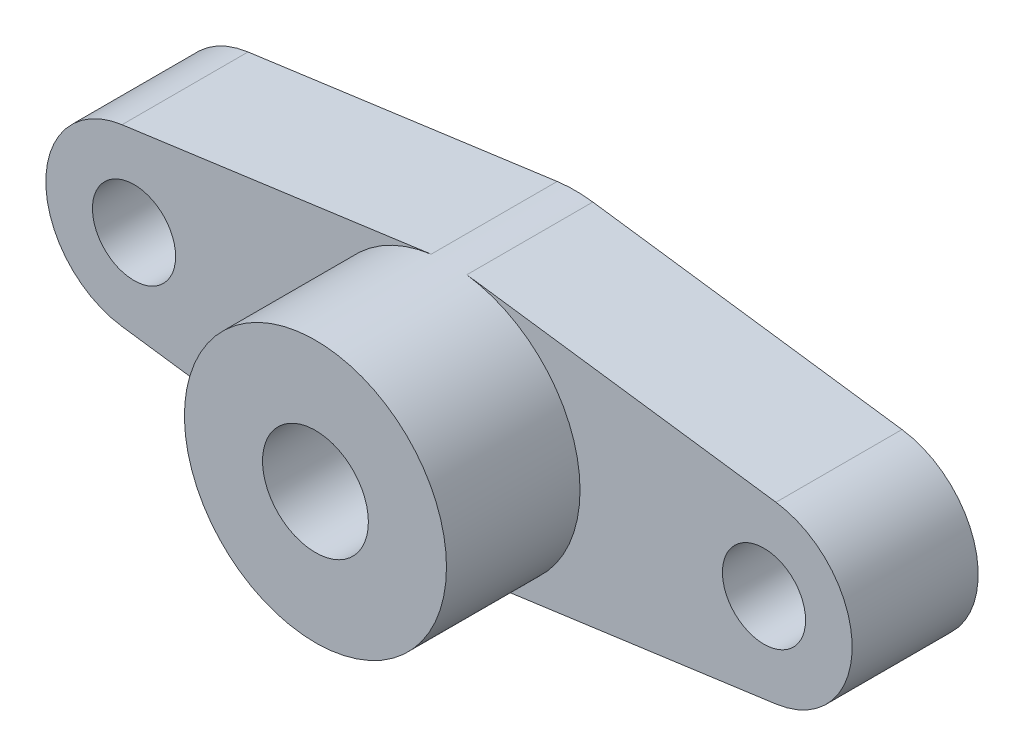
from build123d import *

# Parameters (mm, degrees)
SKETCH_1_W             = 32
SKETCH_1_H             = 10.4
SKETCH_1_R             = 0.5
EXTRUDE_1_DEPTH        = 5
SKETCH_2_R             = 5.2
SKETCH_2_R_2           = 0.5
EXTRUDE_2_DEPTH        = 5.3
CUT_EXTRUDE_1_DEPTH    = 5.3
HOLE_WIZARD_M4_1_D     = 3.3
HOLE_WIZARD_M4_1_DEPTH = 10.1
HOLE_WIZARD_M4_1_TIP   = 0.991420021
HOLE_WIZARD_M5_1_D     = 4.2
HOLE_WIZARD_M5_1_DEPTH = 22.4
HOLE_WIZARD_M5_1_TIP   = 1.2618073


with BuildPart() as part:
    # 草图1 → 凸台-拉伸1 (new body)
    with BuildSketch(Plane.XY):
        Rectangle(SKETCH_1_W, SKETCH_1_H)
        with Locations((-12.5, 0)):
            Circle(SKETCH_1_R, mode=Mode.SUBTRACT)
        with Locations((12.5, 0)):
            Circle(SKETCH_1_R, mode=Mode.SUBTRACT)
        Circle(SKETCH_1_R, mode=Mode.SUBTRACT)
    extrude(amount=EXTRUDE_1_DEPTH)

    # 草图2 → 凸台-拉伸2 (add)
    with BuildSketch(Plane.XY.offset(5)):
        Circle(SKETCH_2_R)
        Circle(SKETCH_2_R_2, mode=Mode.SUBTRACT)
    extrude(amount=EXTRUDE_2_DEPTH)

    # 草图3 → 切除-拉伸1 (cut)
    with BuildSketch(Plane.XY.offset(5)):
        with BuildLine():
            Line((-12.976, 3.46748093), (-0.7072, 5.151685953))
            ThreePointArc((-0.7072, 5.151685953), (-0.354424212, 5.187907428), (0, 5.2))
            Line((0, 5.2), (-16, 5.2))
            Line((-16, 5.2), (-16, 0))
            ThreePointArc((-16, 0), (-15.137802115, 2.300434742), (-12.976, 3.46748093))
        make_face()
        with BuildLine():
            ThreePointArc((0, -5.2), (-0.354424212, -5.187907428), (-0.7072, -5.151685953))
            Line((-0.7072, -5.151685953), (-12.976, -3.46748093))
            ThreePointArc((-12.976, -3.46748093), (-15.137802115, -2.300434742), (-16, 0))
            Line((-16, 0), (-16, -5.2))
            Line((-16, -5.2), (0, -5.2))
        make_face()
        with BuildLine():
            ThreePointArc((0.7072, -5.151685953), (0.354424212, -5.187907428), (0, -5.2))
            Line((0, -5.2), (16, -5.2))
            Line((16, -5.2), (16, 0))
            ThreePointArc((16, 0), (15.137802115, -2.300434742), (12.976, -3.46748093))
            Line((12.976, -3.46748093), (0.7072, -5.151685953))
        make_face()
        with BuildLine():
            Line((16, 5.2), (0, 5.2))
            ThreePointArc((0, 5.2), (0.354424212, 5.187907428), (0.7072, 5.151685953))
            Line((0.7072, 5.151685953), (12.976, 3.46748093))
            ThreePointArc((12.976, 3.46748093), (15.137802115, 2.300434742), (16, 0))
            Line((16, 0), (16, 5.2))
        make_face()
    extrude(amount=-CUT_EXTRUDE_1_DEPTH, mode=Mode.SUBTRACT)

    # M4 螺纹孔1
    with Locations(Plane.XY.offset(5)):
        with Locations((-12.5, 0), (12.5, 0)):
            Hole(HOLE_WIZARD_M4_1_D / 2, depth=HOLE_WIZARD_M4_1_DEPTH)
            with Locations((0, 0, -(HOLE_WIZARD_M4_1_DEPTH + HOLE_WIZARD_M4_1_TIP / 2))):  # 118° drill point
                Cone(0, HOLE_WIZARD_M4_1_D / 2, HOLE_WIZARD_M4_1_TIP, mode=Mode.SUBTRACT)

    # M5 螺纹孔1
    with Locations(Plane.XY.offset(10.3)):
        with Locations((0, 0)):
            Hole(HOLE_WIZARD_M5_1_D / 2, depth=HOLE_WIZARD_M5_1_DEPTH)
            with Locations((0, 0, -(HOLE_WIZARD_M5_1_DEPTH + HOLE_WIZARD_M5_1_TIP / 2))):  # 118° drill point
                Cone(0, HOLE_WIZARD_M5_1_D / 2, HOLE_WIZARD_M5_1_TIP, mode=Mode.SUBTRACT)


solid = part.part
